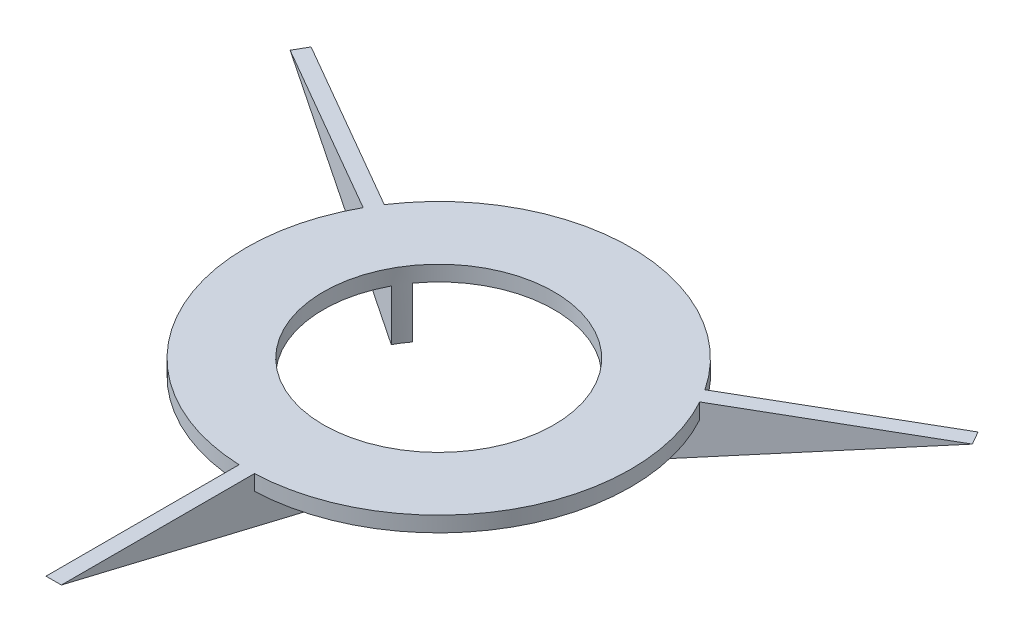
from build123d import *

# Parameters (mm, degrees)
BOSS_EXTRUDE1_DEPTH = 15.24
BOSS_EXTRUDE2_DEPTH = 1.27
CIRPATTERN1_COUNT   = 3
SKETCH4_R           = 31.75
SKETCH4_R_2         = 19.05
BOSS_EXTRUDE3_DEPTH = 2.54
SKETCH5_R           = 19.05
CUT_EXTRUDE1_DEPTH  = 87.362738352


with BuildPart() as part:
    # Sketch2 → Boss-Extrude1 (new body)
    with BuildSketch(Plane(origin=(0, 0, 0), x_dir=(1, 0, 0), z_dir=(0, 1, 0))):
        Polygon((-1.27, 0), (0, 2.199704526), (1.27, 0), align=None)
    extrude(amount=BOSS_EXTRUDE1_DEPTH)

    # Sketch3 → Boss-Extrude2 (add, symmetric)
    with BuildSketch(Plane(origin=(0, 0, 0), x_dir=(0, 0, -1), z_dir=(1, 0, 0))):
        Polygon((0, 15.24), (-63.627, 15.24), (0, 0), align=None)
    boss_extrude2 = extrude(amount=BOSS_EXTRUDE2_DEPTH, both=True)

    # CirPattern1: Boss-Extrude2 ×3 about axis
    cirpattern1_axis = Axis((0, 0, -0.733234842), (0, -1, 0))
    for i in range(1, CIRPATTERN1_COUNT):
        add(boss_extrude2.rotate(cirpattern1_axis, i * 360 / CIRPATTERN1_COUNT))

    # Sketch4 → Boss-Extrude3 (add)
    with BuildSketch(Plane(origin=(0, 15.24, 0), x_dir=(1, 0, 0), z_dir=(0, 1, 0))):
        Circle(SKETCH4_R)
        Circle(SKETCH4_R_2, mode=Mode.SUBTRACT)
    extrude(amount=-BOSS_EXTRUDE3_DEPTH)

    # Sketch5 → Cut-Extrude1 (cut, through all)
    with BuildSketch(Plane(origin=(0, 15.24, 0), x_dir=(1, 0, 0), z_dir=(0, 1, 0))):
        Circle(SKETCH5_R)
    extrude(amount=-CUT_EXTRUDE1_DEPTH, mode=Mode.SUBTRACT)


solid = part.part
